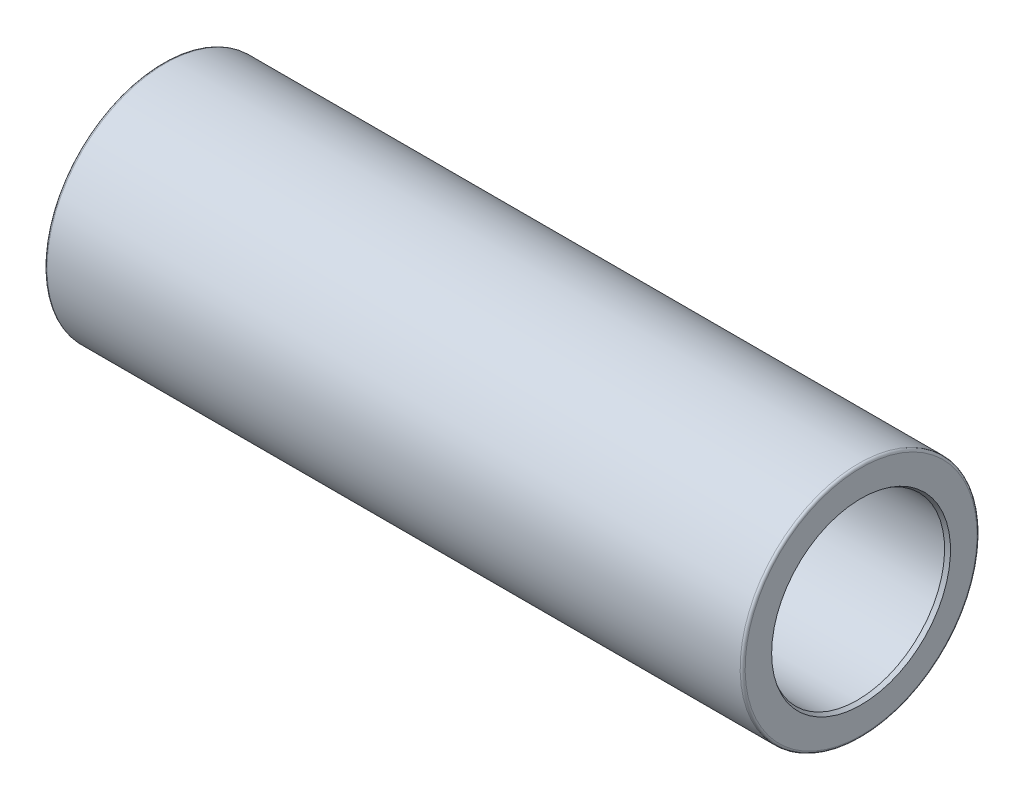
from build123d import *


with BuildPart() as part:
    # Sketch1 → Base-Revolve (revolve)
    with BuildSketch(Plane.XY):
        with BuildLine():
            Line((-140, 35), (-140, 46.5))
            ThreePointArc((-140, 46.5), (-139.707106781, 47.207106781), (-139, 47.5))
            Line((-139, 47.5), (139, 47.5))
            ThreePointArc((139, 47.5), (139.707106781, 47.207106781), (140, 46.5))
            Line((140, 46.5), (140, 35))
            Line((140, 35), (73.462610506, 35))
            Line((73.462610506, 35), (71.5, 36))
            Line((71.5, 36), (69.5, 36))
            Line((69.5, 36), (69.5, 34))
            Line((69.5, 34), (60.176326981, 34))
            ThreePointArc((60.176326981, 34), (60.002678803, 34.015192247), (59.834306837, 34.060307379))
            Line((59.834306837, 34.060307379), (50.549522195, 37.439692621))
            ThreePointArc((50.549522195, 37.439692621), (50.381150229, 37.484807753), (50.207502051, 37.5))
            Line((50.207502051, 37.5), (-50.207502051, 37.5))
            ThreePointArc((-50.207502051, 37.5), (-50.381150229, 37.484807753), (-50.549522195, 37.439692621))
            Line((-50.549522195, 37.439692621), (-59.834306837, 34.060307379))
            ThreePointArc((-59.834306837, 34.060307379), (-60.002678803, 34.015192247), (-60.176326981, 34))
            Line((-60.176326981, 34), (-69.5, 34))
            Line((-69.5, 34), (-69.5, 36))
            Line((-69.5, 36), (-71.5, 36))
            Line((-71.5, 36), (-73.462610506, 35))
            Line((-73.462610506, 35), (-140, 35))
        make_face()
    revolve(axis=Axis((-140, 0, 0), (1, 0, 0)))

    # Sketch5 → 2.5 x 30 gr reifning (revolve, cut)
    with BuildSketch(Plane.XY):
        Polygon((140, 35.866025404), (138.5, 35), (140, 35), align=None)
        Polygon((-140, 35), (-140, 35.866025404), (-138.5, 35), align=None)
    revolve(axis=Axis((0, 0, 0), (1, 0, 0)), mode=Mode.SUBTRACT)


solid = part.part
